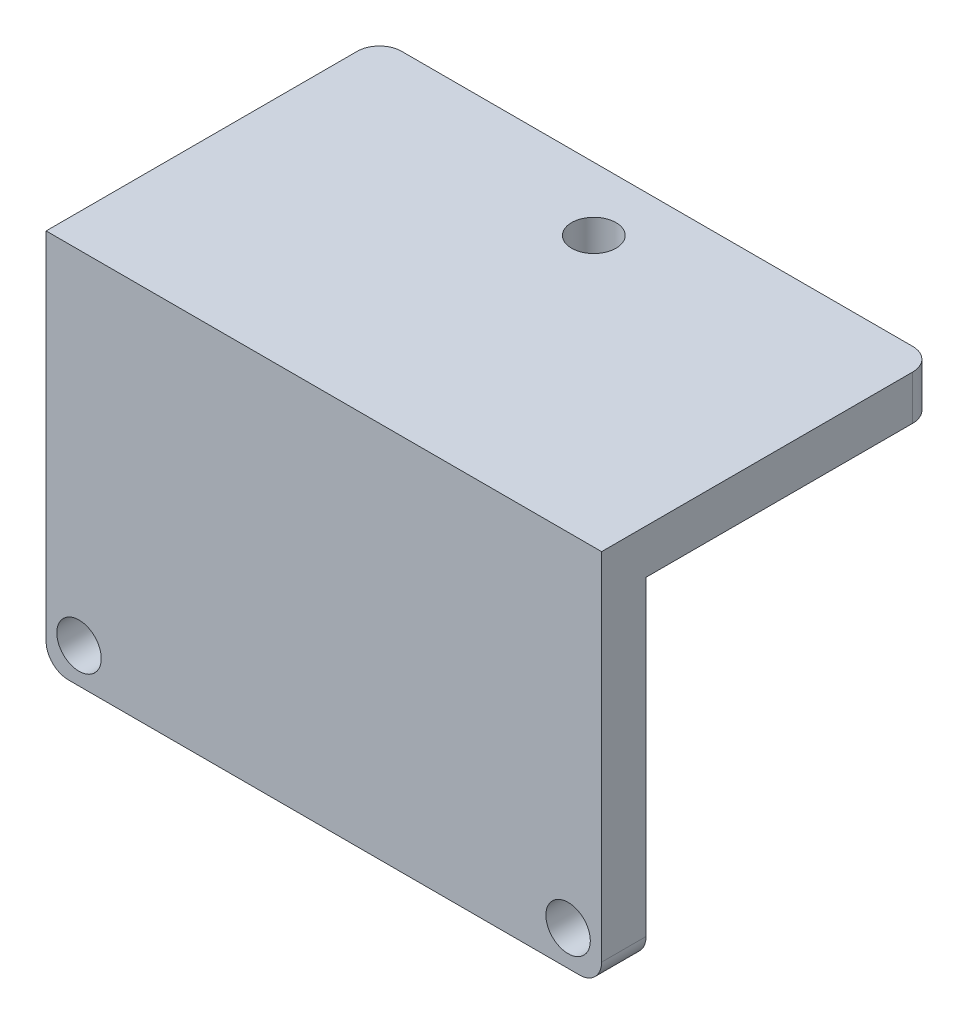
from build123d import *

# Parameters (mm, degrees)
SKETCH1_W           = 25
SKETCH1_H           = 15
SKETCH1_R           = 1
BOSS_EXTRUDE1_DEPTH = 2
FILLET5_R           = 1
SKETCH2_W           = 25
SKETCH2_H           = 15
BOSS_EXTRUDE2_DEPTH = 2
FILLET6_R           = 1
FILLET7_R           = 1
SKETCH3_R           = 1
CUT_EXTRUDE1_DEPTH  = 32


with BuildPart() as part:
    # Sketch1 → Boss-Extrude1 (new body)
    with BuildSketch(Plane.XY):
        with Locations((-12.5, -7.5)):
            Rectangle(SKETCH1_W, SKETCH1_H)
        with Locations((-23.519315542, -13.423068426)):
            Circle(SKETCH1_R, mode=Mode.SUBTRACT)
        with Locations((-1.508210611, -13.423068426)):
            Circle(SKETCH1_R, mode=Mode.SUBTRACT)
    extrude(amount=BOSS_EXTRUDE1_DEPTH)

    # Fillet5
    fillet5_edges = [part.edges().sort_by_distance(p)[0] for p in [
        (0, -15, 1),
        (-25, -15, 1),
    ]]
    fillet(fillet5_edges, radius=FILLET5_R)

    # Sketch2 → Boss-Extrude2 (add)
    with BuildSketch(Plane(origin=(0, 0, 0), x_dir=(1, 0, 0), z_dir=(0, 1, 0))):
        with Locations((-12.5, 5.5)):
            Rectangle(SKETCH2_W, SKETCH2_H)
    extrude(amount=BOSS_EXTRUDE2_DEPTH)

    # Fillet6
    fillet6_edges = [part.edges().sort_by_distance(p)[0] for p in [
        (-25, 1, -13),
    ]]
    fillet(fillet6_edges, radius=FILLET6_R)

    # Fillet7
    fillet7_edges = [part.edges().sort_by_distance(p)[0] for p in [
        (0, 1, -13),
    ]]
    fillet(fillet7_edges, radius=FILLET7_R)

    # Sketch3 → Cut-Extrude1 (cut)
    with BuildSketch(Plane(origin=(0, 2, 0), x_dir=(1, 0, 0), z_dir=(0, 1, 0))):
        with Locations((-12.5, 10.148186861)):
            Circle(SKETCH3_R)
    extrude(amount=-CUT_EXTRUDE1_DEPTH, mode=Mode.SUBTRACT)


solid = part.part
